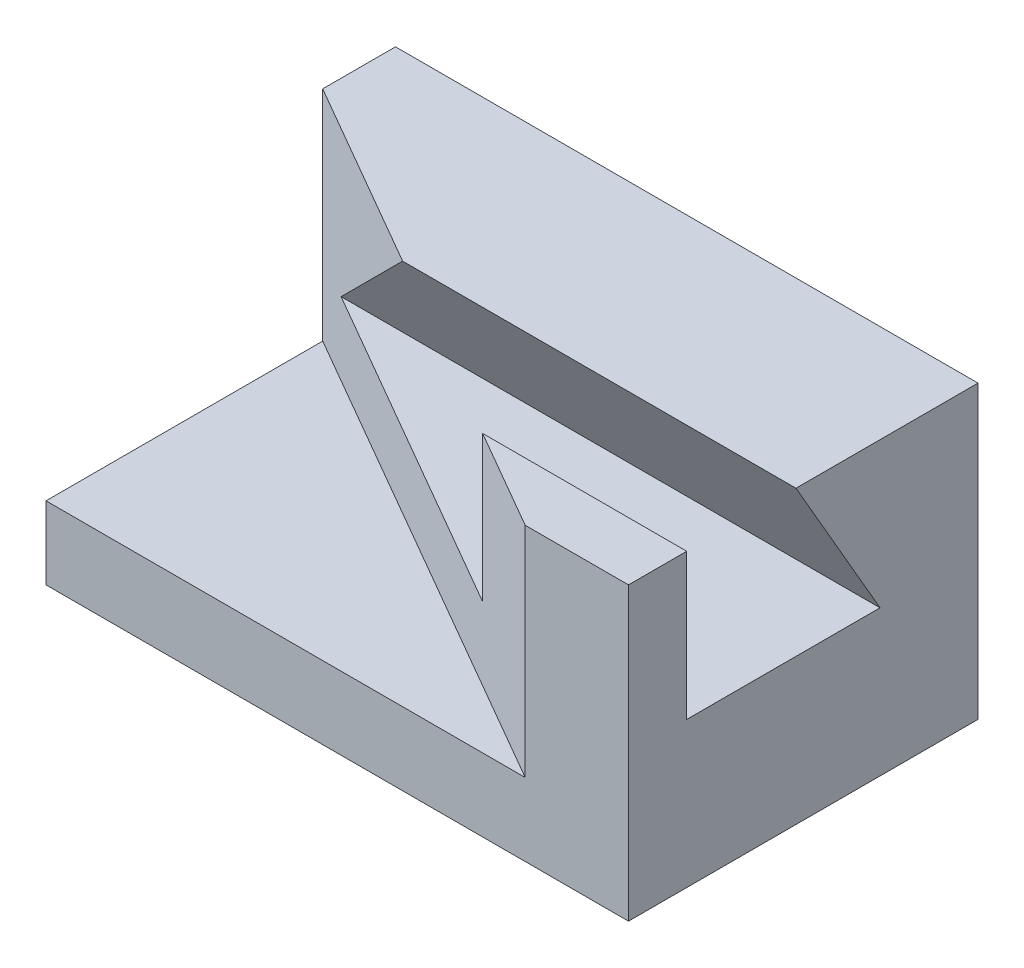
from build123d import *

# Parameters (mm, degrees)
SKIZZE1_W                       = 80
SKIZZE1_H                       = 48
AUFSATZ_LINEAR_AUSTRAGEN1_DEPTH = 40
SCHNITT_LINEAR_AUSTRAGEN1_DEPTH = 30
SCHNITT_LINEAR_AUSTRAGEN2_DEPTH = 81


with BuildPart() as part:
    # Skizze1 → Aufsatz-Linear austragen1 (new body)
    with BuildSketch(Plane(origin=(0, 0, 0), x_dir=(1, 0, 0), z_dir=(0, 1, 0))):
        with Locations((-40, 24)):
            Rectangle(SKIZZE1_W, SKIZZE1_H)
    extrude(amount=AUFSATZ_LINEAR_AUSTRAGEN1_DEPTH)

    # Skizze2 → Schnitt-Linear austragen1 (cut)
    with BuildSketch(Plane(origin=(0, 40, 0), x_dir=(1, 0, 0), z_dir=(0, 1, 0))):
        Polygon((-80, 0), (-80, 38), (-14.182069312, 0), align=None)
    extrude(amount=-SCHNITT_LINEAR_AUSTRAGEN1_DEPTH, mode=Mode.SUBTRACT)

    # Skizze4 → Schnitt-Linear austragen2 (cut, through all)
    with BuildSketch(Plane(origin=(0, 0, 0), x_dir=(0, 0, -1), z_dir=(1, 0, 0))):
        Polygon((23, 40), (34.547005384, 20), (8, 20), (8, 40), align=None)
    extrude(amount=-SCHNITT_LINEAR_AUSTRAGEN2_DEPTH, mode=Mode.SUBTRACT)


solid = part.part
